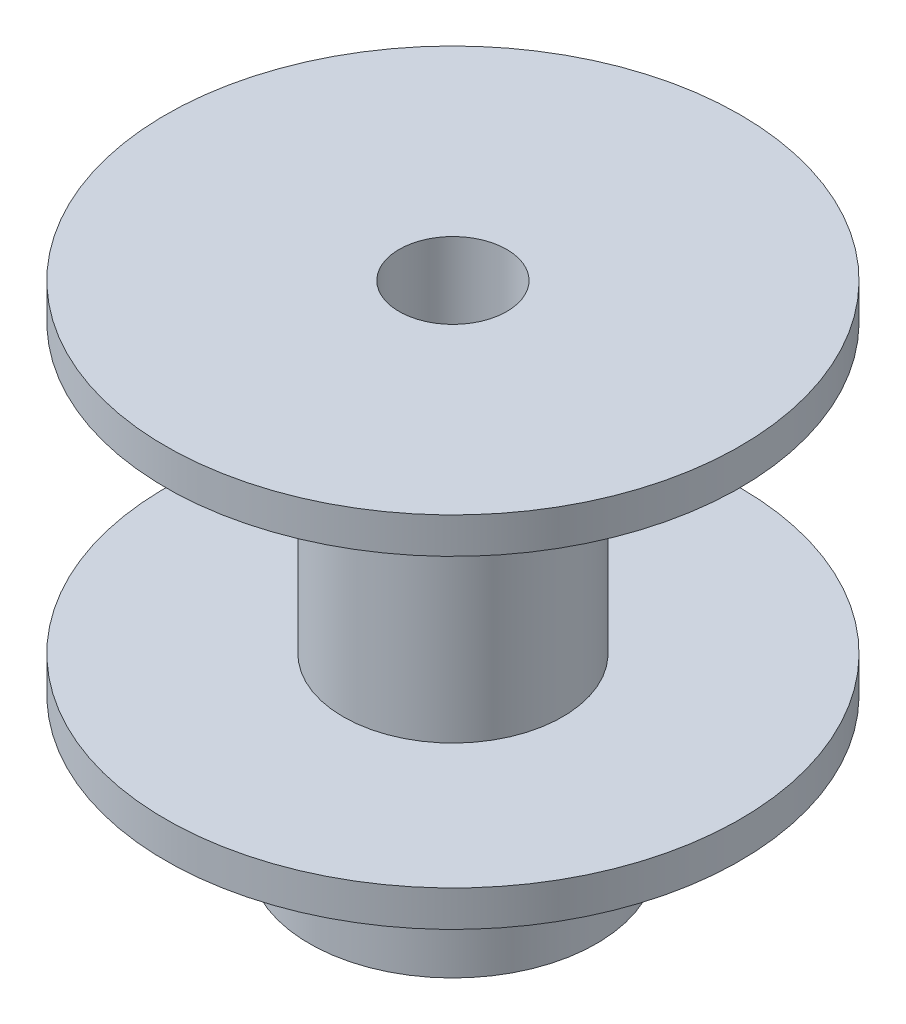
from build123d import *


with BuildPart() as part:
    # Sketch1 → Revolve1 (revolve)
    with BuildSketch(Plane.XY):
        Polygon((-2.38125, 15.875), (-12.7, 15.875), (-12.7, 14.2875), (-4.8514, 14.2875), (-4.8514, 1.5875), (-12.7, 1.5875), (-12.7, 0), (-6.35, 0), (-6.35, -6.35), (-2.38125, -6.35), align=None)
    revolve(axis=Axis((0, -8.976404057, 0), (0, 1, 0)))


solid = part.part
